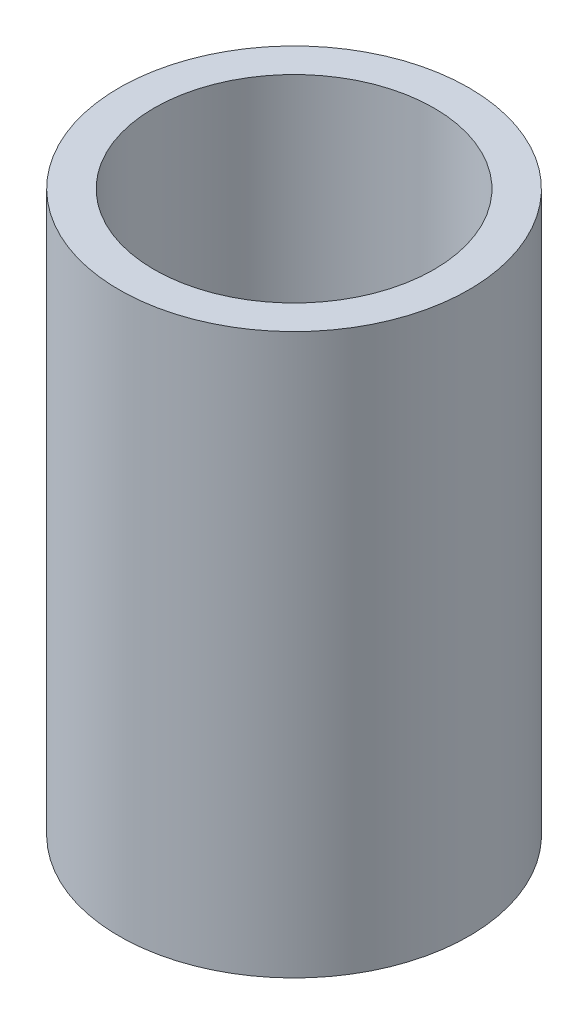
from build123d import *

# Parameters (mm, degrees)
SKETCH1_W = 1.5
SKETCH1_H = 24


with BuildPart() as part:
    # Sketch1 → Revolve1 (revolve)
    with BuildSketch(Plane.XY):
        with Locations((6.75, 12)):
            Rectangle(SKETCH1_W, SKETCH1_H)
    revolve(axis=Axis((0, 0, 0), (0, 1, 0)))


solid = part.part
